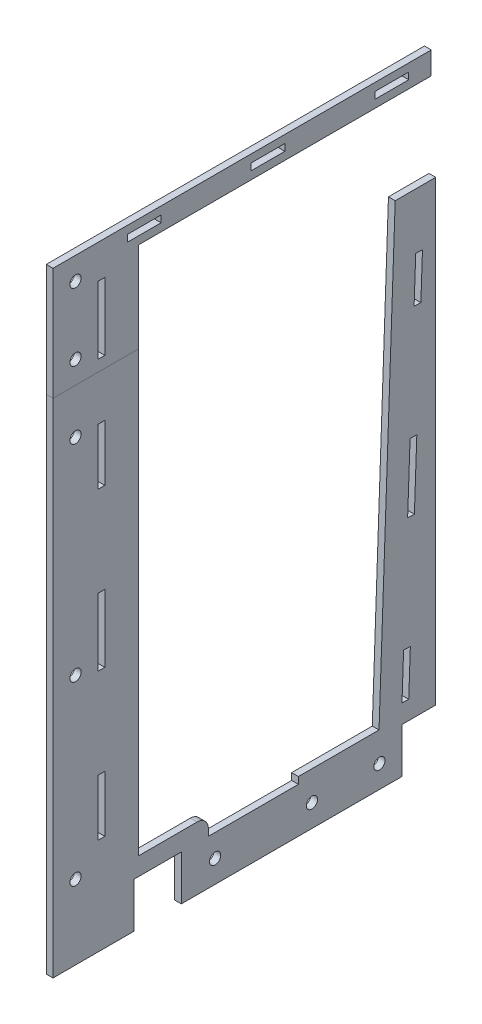
from build123d import *

# Parameters (mm, degrees)
SKETCH1_W           = 132
SKETCH1_H           = 200
BOSS_EXTRUDE1_DEPTH = 3
SKETCH5_W           = 170
SKETCH5_H           = 223
BOSS_EXTRUDE2_DEPTH = 3
CUT_EXTRUDE1_DEPTH  = 4
SKETCH3_R           = 2.5
CUT_EXTRUDE2_DEPTH  = 4
SKETCH6_W           = 21
SKETCH6_H           = 20
CUT_EXTRUDE4_DEPTH  = 4
SKETCH7_W           = 15
SKETCH7_H           = 20
CUT_EXTRUDE5_DEPTH  = 4
CUT_EXTRUDE3_DEPTH  = 4
SKETCH8_W           = 3
SKETCH8_H           = 25
SKETCH8_H_2         = 30
CUT_EXTRUDE6_DEPTH  = 4
SKETCH9_R           = 2.5
CUT_EXTRUDE7_DEPTH  = 4
BOSS_EXTRUDE3_DEPTH = 3
SKETCH11_W          = 15
SKETCH11_H          = 3
CUT_EXTRUDE8_DEPTH  = 3
SKETCH12_R          = 2.5
CUT_EXTRUDE9_DEPTH  = 10
SKETCH13_W          = 3
SKETCH13_H          = 30
CUT_EXTRUDE10_DEPTH = 10


with BuildPart() as part:
    # Sketch1 → Boss-Extrude1 (new body)
    with BuildSketch(Plane(origin=(0, 0, 0), x_dir=(0, 0, -1), z_dir=(1, 0, 0))):
        with Locations((66, 100)):
            Rectangle(SKETCH1_W, SKETCH1_H)
    extrude(amount=BOSS_EXTRUDE1_DEPTH)

    # Sketch5 → Boss-Extrude2 (add, through all)
    with BuildSketch(Plane(origin=(3, 0, 0), x_dir=(0, 0, -1), z_dir=(1, 0, 0))):
        with Locations((62, 88.5)):
            Rectangle(SKETCH5_W, SKETCH5_H)
    extrude(amount=-BOSS_EXTRUDE2_DEPTH)

    # Sketch2 → Cut-Extrude1 (cut, through all)
    with BuildSketch(Plane(origin=(3, 0, 0), x_dir=(0, 0, -1), z_dir=(1, 0, 0))):
        Polygon((135, 5.2), (132.001935036, 5.307733341), (132.720157307, 25.294833099), (135.718222271, 25.187099759), align=None)
        Polygon((138.106824336, 175.198081291), (141.1048893, 175.09034795), (140.386667029, 155.103248191), (137.388602066, 155.210981532), align=None)
        Polygon((135.593046389, 105.243232135), (138.591111353, 105.135498794), (137.513777947, 75.154849156), (134.515712983, 75.262582497), align=None)
    extrude(amount=-CUT_EXTRUDE1_DEPTH, mode=Mode.SUBTRACT)

    # Sketch3 → Cut-Extrude2 (cut, through all)
    with BuildSketch(Plane(origin=(3, 0, 0), x_dir=(0, 0, -1), z_dir=(1, 0, 0))):
        with Locations((122, -13)):
            Circle(SKETCH3_R)
        with Locations((92, -13)):
            Circle(SKETCH3_R)
        with Locations((-13, 10)):
            Circle(SKETCH3_R)
        with Locations((49, -13)):
            Circle(SKETCH3_R)
    extrude(amount=-CUT_EXTRUDE2_DEPTH, mode=Mode.SUBTRACT)

    # Sketch6 → Cut-Extrude4 (cut, through all)
    with BuildSketch(Plane(origin=(3, 0, 0), x_dir=(0, 0, -1), z_dir=(1, 0, 0))):
        with Locations((23.5, -13)):
            Rectangle(SKETCH6_W, SKETCH6_H)
    extrude(amount=-CUT_EXTRUDE4_DEPTH, mode=Mode.SUBTRACT)

    # Sketch7 → Cut-Extrude5 (cut, through all)
    with BuildSketch(Plane(origin=(3, 0, 0), x_dir=(0, 0, -1), z_dir=(1, 0, 0))):
        with Locations((139.5, -13)):
            Rectangle(SKETCH7_W, SKETCH7_H)
    extrude(amount=-CUT_EXTRUDE5_DEPTH, mode=Mode.SUBTRACT)

    # Sketch4 → Cut-Extrude3 (cut, through all)
    with BuildSketch(Plane(origin=(3, 0, 0), x_dir=(0, 0, -1), z_dir=(1, 0, 0))):
        with BuildLine():
            Line((128.991609431, 200), (15, 200))
            Line((15, 200), (15, 5))
            Line((15, 5), (41, 5))
            ThreePointArc((41, 5), (44.535533906, 3.535533906), (46, 0))
            Line((46, 0), (46, -3))
            Line((46, -3), (86, -3))
            Line((86, -3), (86, 0))
            Line((86, 0), (121.804751115, 0))
            Line((121.804751115, 0), (128.991609431, 200))
        make_face()
    extrude(amount=-CUT_EXTRUDE3_DEPTH, mode=Mode.SUBTRACT)

    # Sketch8 → Cut-Extrude6 (cut, through all)
    with BuildSketch(Plane(origin=(3, 0, 0), x_dir=(0, 0, -1), z_dir=(1, 0, 0))):
        with Locations((-1.5, 167.5)):
            Rectangle(SKETCH8_W, SKETCH8_H)
        with Locations((-1.5, 100)):
            Rectangle(SKETCH8_W, SKETCH8_H_2)
        with Locations((-1.5, 32.5)):
            Rectangle(SKETCH8_W, SKETCH8_H)
    extrude(amount=-CUT_EXTRUDE6_DEPTH, mode=Mode.SUBTRACT)

    # Sketch9 → Cut-Extrude7 (cut, through all)
    with BuildSketch(Plane(origin=(3, 0, 0), x_dir=(0, 0, -1), z_dir=(1, 0, 0))):
        with Locations((-13, 180)):
            Circle(SKETCH9_R)
        with Locations((-13, 88.5)):
            Circle(SKETCH9_R)
    extrude(amount=-CUT_EXTRUDE7_DEPTH, mode=Mode.SUBTRACT)


with BuildPart() as body_2:
    # Sketch10 → Boss-Extrude3 (new body)
    with BuildSketch(Plane(origin=(3, 0, 0), x_dir=(0, 0, -1), z_dir=(1, 0, 0))):
        Polygon((15, 240), (15, 200), (-23, 200), (-23, 250), (145, 250), (145, 240), align=None)
    extrude(amount=-BOSS_EXTRUDE3_DEPTH)

    # Sketch11 → Cut-Extrude8 (cut)
    with BuildSketch(Plane(origin=(3, 0, 0), x_dir=(0, 0, -1), z_dir=(1, 0, 0))):
        with Locations((127.5, 245)):
            Rectangle(SKETCH11_W, SKETCH11_H)
        with Locations((72.5, 245)):
            Rectangle(SKETCH11_W, SKETCH11_H)
        with Locations((17.5, 245)):
            Rectangle(SKETCH11_W, SKETCH11_H)
    extrude(amount=-CUT_EXTRUDE8_DEPTH, mode=Mode.SUBTRACT)

    # Sketch12 → Cut-Extrude9 (cut)
    with BuildSketch(Plane(origin=(3, 0, 0), x_dir=(0, 0, -1), z_dir=(1, 0, 0))):
        with Locations((-13, 240)):
            Circle(SKETCH12_R)
        with Locations((-13, 210)):
            Circle(SKETCH12_R)
    extrude(amount=-CUT_EXTRUDE9_DEPTH, mode=Mode.SUBTRACT)

    # Sketch13 → Cut-Extrude10 (cut)
    with BuildSketch(Plane(origin=(3, 0, 0), x_dir=(0, 0, -1), z_dir=(1, 0, 0))):
        with Locations((-1.5, 220)):
            Rectangle(SKETCH13_W, SKETCH13_H)
    extrude(amount=-CUT_EXTRUDE10_DEPTH, mode=Mode.SUBTRACT)


solid = Compound([part.part, body_2.part])
